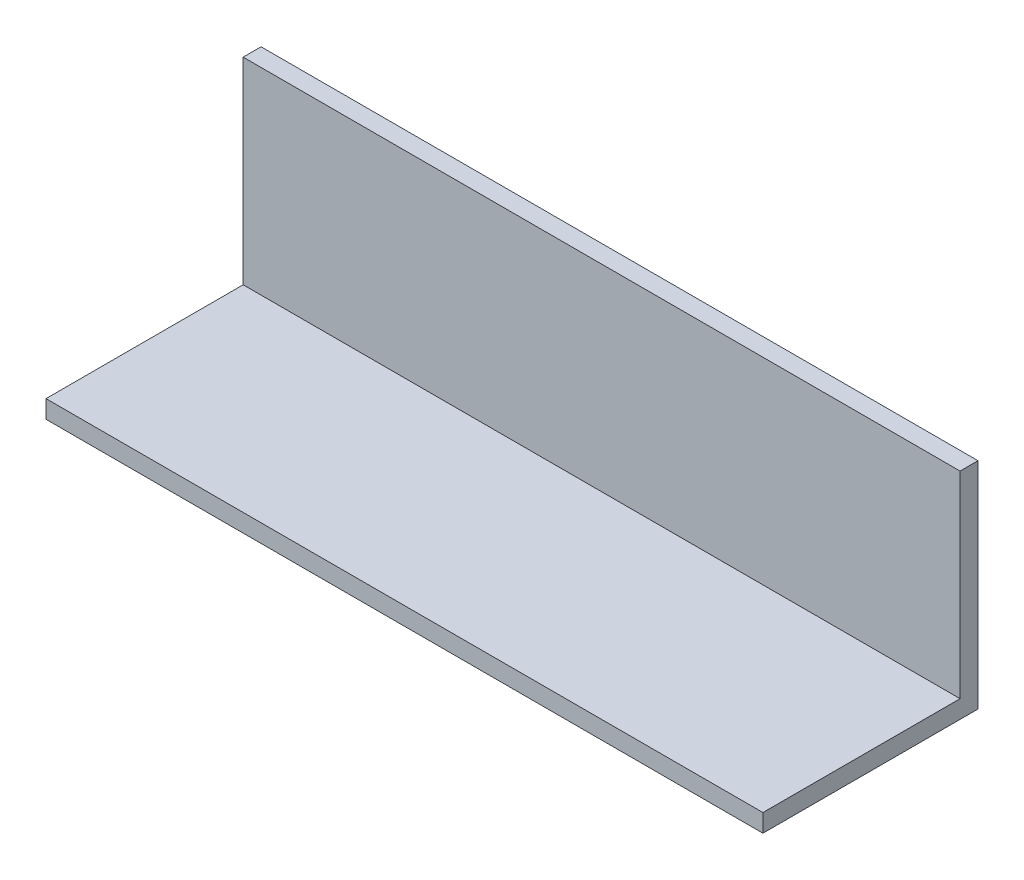
from build123d import *

# Parameters (mm, degrees)
SKETCH1_W           = 127
SKETCH1_H           = 38.1
BOSS_EXTRUDE1_DEPTH = 38.1
SKETCH2_W           = 127
SKETCH2_H           = 34.925
CUT_EXTRUDE1_DEPTH  = 34.925


with BuildPart() as part:
    # Sketch1 → Boss-Extrude1 (new body)
    with BuildSketch(Plane.XY):
        with Locations((61.654, -18.33825)):
            Rectangle(SKETCH1_W, SKETCH1_H)
    extrude(amount=BOSS_EXTRUDE1_DEPTH)

    # Sketch2 → Cut-Extrude1 (cut)
    with BuildSketch(Plane.XY.offset(38.1)):
        with Locations((61.654, -16.75075)):
            Rectangle(SKETCH2_W, SKETCH2_H)
    extrude(amount=-CUT_EXTRUDE1_DEPTH, mode=Mode.SUBTRACT)


solid = part.part
